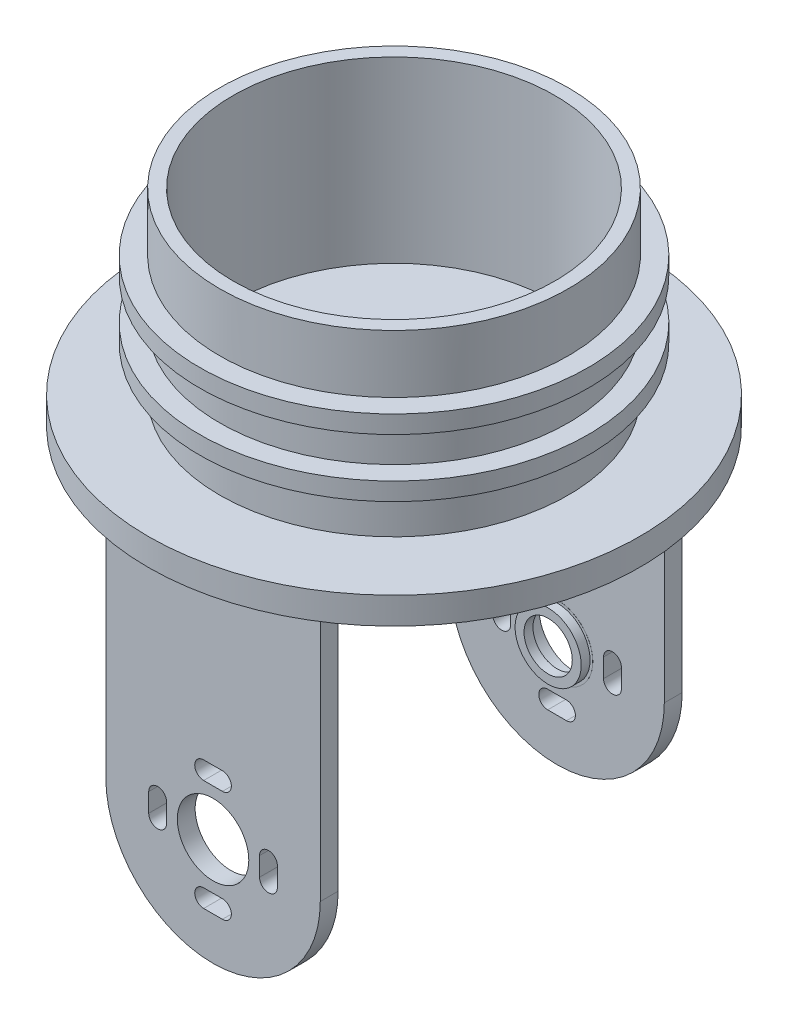
from build123d import *

# Parameters (mm, degrees)
SKETCH_1_R               = 19.5
SKETCH_1_R_2             = 18
EXTRUDE_1_DEPTH          = 20
SKETCH_3_R               = 27.5
EXTRUDE_2_DEPTH          = 3
SKETCH_25_R              = 21.75
SKETCH_25_R_2            = 19.5
EXTRUDE_12_DEPTH         = 2
EXTRUDE_START            = -1
SKETCH_26_R              = 21.75
SKETCH_26_R_2            = 19.5
EXTRUDE_13_DEPTH         = 2
SKETCH_28_R              = 4
EXTRUDE_14_DEPTH         = 2
PATTERN_LINEAR_1_COUNT   = 2
PATTERN_LINEAR_1_PITCH   = 38.5
SKETCH_30_W              = 11
SKETCH_30_H              = 7
EXTRUDE_16_DEPTH         = 10
SKETCH_29_W              = 9
SKETCH_29_H              = 5
CUT_EXTRUDE_2_DEPTH      = 10
CUT_EXTRUDE_2_DEPTH_BACK = 10
SKETCH_31_R              = 3.7
SKETCH_31_R_2            = 2.7
EXTRUDE_17_DEPTH         = 1
SKETCH_32_R              = 4
SKETCH_32_R_2            = 3.7
EXTRUDE_18_DEPTH         = 0.01


with BuildPart() as part:
    # 草圖1 → 填料-伸長1 (new body)
    with BuildSketch(Plane(origin=(0, 0, 0), x_dir=(1, 0, 0), z_dir=(0, 1, 0))):
        Circle(SKETCH_1_R)
        Circle(SKETCH_1_R_2, mode=Mode.SUBTRACT)
    extrude(amount=EXTRUDE_1_DEPTH)

    # 草圖3 → 填料-伸長2 (add)
    with BuildSketch(Plane.XZ):
        Circle(SKETCH_3_R)
    extrude(amount=EXTRUDE_2_DEPTH)

    # 草圖25 → 填料-伸長12 (add)
    with BuildSketch(Plane(origin=(0, 7, 0), x_dir=(-1, 0, 0), z_dir=(0, -1, 0))):
        Circle(SKETCH_25_R)
        Circle(SKETCH_25_R_2, mode=Mode.SUBTRACT)
    extrude(amount=EXTRUDE_12_DEPTH)

    # 草圖26 → 填料-伸長13 (add)
    with BuildSketch(Plane(origin=(0, 10.5, 0), x_dir=(-1, 0, 0), z_dir=(0, -1, 0)).offset(EXTRUDE_START)):
        Circle(SKETCH_26_R)
        Circle(SKETCH_26_R_2, mode=Mode.SUBTRACT)
    extrude(amount=-EXTRUDE_13_DEPTH)

    # 草圖28 → 填料-伸長14 (add)
    with BuildSketch(Plane.XY.offset(-18.25)):
        with BuildLine():
            Line((-12, -3), (12, -3))
            Line((12, -3), (12, -33))
            ThreePointArc((12, -33), (0, -45), (-12, -33))
            Line((-12, -33), (-12, -3))
        make_face()
        with Locations((0, -33)):
            Circle(SKETCH_28_R, mode=Mode.SUBTRACT)
        with BuildLine():
            Line((-1.05, -25.8), (1.05, -25.8))
            ThreePointArc((1.05, -25.8), (2.05, -26.8), (1.05, -27.8))
            Line((1.05, -27.8), (-1.05, -27.8))
            ThreePointArc((-1.05, -27.8), (-2.05, -26.8), (-1.05, -25.8))
        make_face(mode=Mode.SUBTRACT)
        with BuildLine():
            Line((7.2, -31.95), (7.2, -34.05))
            ThreePointArc((7.2, -34.05), (6.2, -35.05), (5.2, -34.05))
            Line((5.2, -34.05), (5.2, -31.95))
            ThreePointArc((5.2, -31.95), (6.2, -30.95), (7.2, -31.95))
        make_face(mode=Mode.SUBTRACT)
        with BuildLine():
            Line((-1.05, -40.2), (1.05, -40.2))
            ThreePointArc((1.05, -40.2), (2.05, -39.2), (1.05, -38.2))
            Line((1.05, -38.2), (-1.05, -38.2))
            ThreePointArc((-1.05, -38.2), (-2.05, -39.2), (-1.05, -40.2))
        make_face(mode=Mode.SUBTRACT)
        with BuildLine():
            Line((-7.2, -31.95), (-7.2, -34.05))
            ThreePointArc((-7.2, -34.05), (-6.2, -35.05), (-5.2, -34.05))
            Line((-5.2, -34.05), (-5.2, -31.95))
            ThreePointArc((-5.2, -31.95), (-6.2, -30.95), (-7.2, -31.95))
        make_face(mode=Mode.SUBTRACT)
    extrude_14 = extrude(amount=-EXTRUDE_14_DEPTH)

    # 直線複製排列1: 填料-伸長14 ×2
    with Locations(*[(0, 0, i * PATTERN_LINEAR_1_PITCH) for i in range(1, PATTERN_LINEAR_1_COUNT)]):
        add(extrude_14)

    # 草圖30 → 填料-伸長16 (add)
    with BuildSketch(Plane(origin=(0, 0, 0), x_dir=(1, 0, 0), z_dir=(0, 1, 0))):
        with Locations((0, -12.44566721)):
            Rectangle(SKETCH_30_W, SKETCH_30_H)
    extrude(amount=EXTRUDE_16_DEPTH)

    # 草圖29 → 除料-伸長2 (cut, two sides)
    with BuildSketch(Plane(origin=(0, 0, 0), x_dir=(1, 0, 0), z_dir=(0, 1, 0))) as cut_extrude_2_sk:
        with Locations((0, -12.44566721)):
            Rectangle(SKETCH_29_W, SKETCH_29_H)
    extrude(amount=CUT_EXTRUDE_2_DEPTH, mode=Mode.SUBTRACT)
    extrude(cut_extrude_2_sk.sketch, amount=-CUT_EXTRUDE_2_DEPTH_BACK, mode=Mode.SUBTRACT)


with BuildPart() as body_2:
    # 草圖31 → 填料-伸長17 (new body)
    with BuildSketch(Plane.XY.offset(-18.25)):
        with Locations((0, -33)):
            Circle(SKETCH_31_R)
        with Locations((0, -33)):
            Circle(SKETCH_31_R_2, mode=Mode.SUBTRACT)
    extrude(amount=EXTRUDE_17_DEPTH)

    # 草圖32 → 填料-伸長18 (add)
    with BuildSketch(Plane.XY.offset(-18.25)):
        with Locations((0, -33)):
            Circle(SKETCH_32_R)
        with Locations((0, -33)):
            Circle(SKETCH_32_R_2, mode=Mode.SUBTRACT)
    extrude(amount=EXTRUDE_18_DEPTH)


solid = Compound([part.part, body_2.part])
